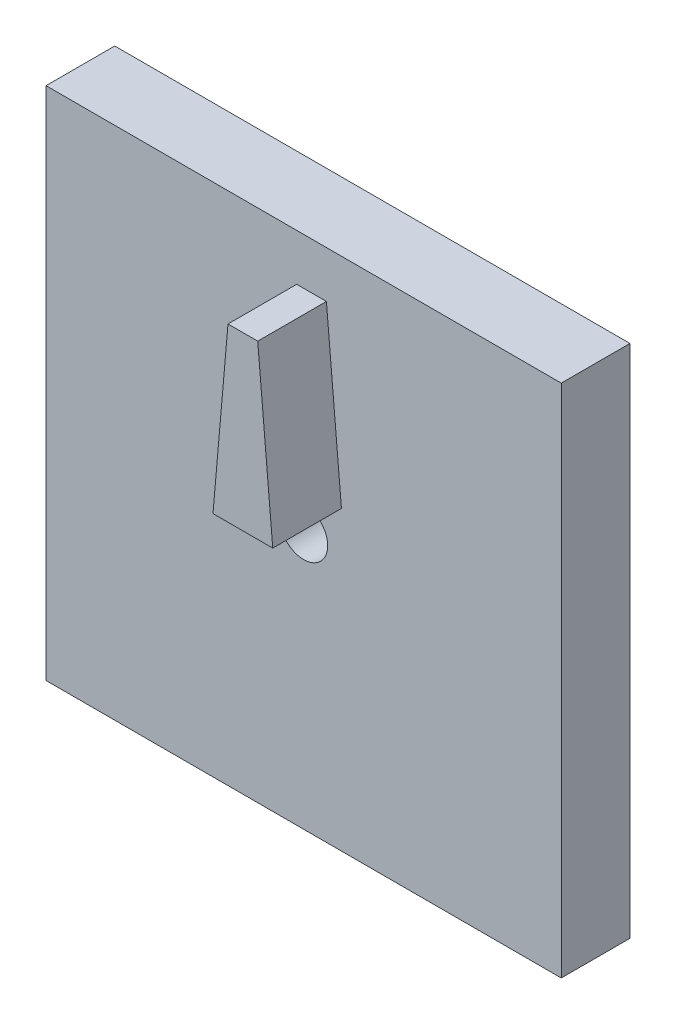
from build123d import *

# Parameters (mm, degrees)
SKETCH1_W      = 19.05
SKETCH1_H      = 19.05
SKETCH1_R      = 0.889
EXTRUDE1_DEPTH = 2.54
EXTRUDE2_DEPTH = 2.54


with BuildPart() as part:
    # Sketch1 → Extrude1 (new body)
    with BuildSketch(Plane.XY):
        Rectangle(SKETCH1_W, SKETCH1_H)
        Circle(SKETCH1_R, mode=Mode.SUBTRACT)
    extrude(amount=-EXTRUDE1_DEPTH)

    # Sketch2 → Extrude2 (add)
    with BuildSketch(Plane.XY):
        Polygon((0.841446987, 7.7978), (1.397, 1.4478), (-0.8128, 1.4478), (-0.257246987, 7.7978), align=None)
    extrude(amount=EXTRUDE2_DEPTH)


solid = part.part
